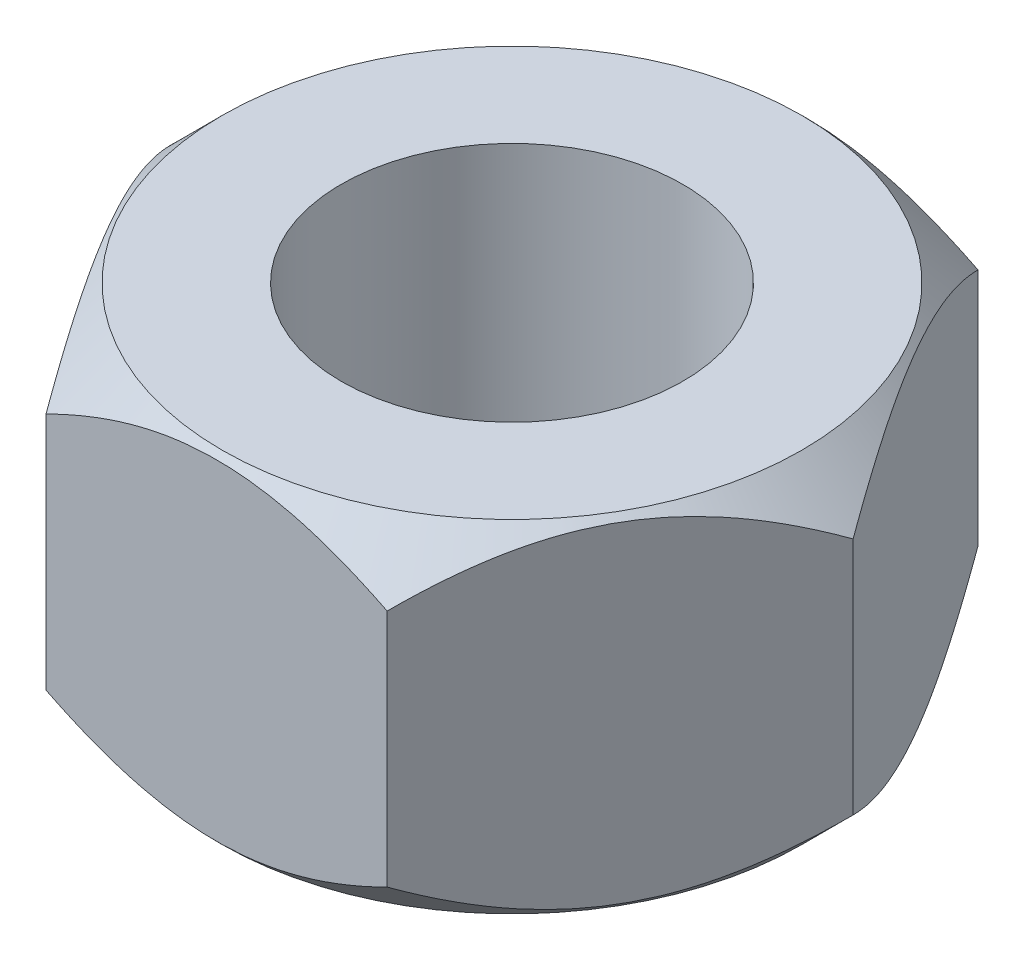
from build123d import *

# Parameters (mm, degrees)
SKETCH5_R           = 10
BOSS_EXTRUDE1_DEPTH = 20


with BuildPart() as part:
    # Sketch5 → Boss-Extrude1 (new body)
    with BuildSketch(Plane(origin=(0, 0, 0), x_dir=(1, 0, 0), z_dir=(0, 1, 0))):
        Polygon((19.976319314, 0), (9.988159657, 17.3), (-9.988159657, 17.3), (-19.976319314, 0), (-9.988159657, -17.3), (9.988159657, -17.3), align=None)
        Circle(SKETCH5_R, mode=Mode.SUBTRACT)
    extrude(amount=BOSS_EXTRUDE1_DEPTH)

    # Sketch6 → Cut-Revolve1 (revolve, cut)
    with BuildSketch(Plane.XY):
        Polygon((19.976319314, 0), (16.976319314, 0), (19.976319314, 3), align=None)
        Polygon((19.976319314, 20), (16.976319314, 20), (19.976319314, 17), align=None)
    revolve(axis=Axis((0, 0, 0), (0, 1, 0)), mode=Mode.SUBTRACT)


solid = part.part
